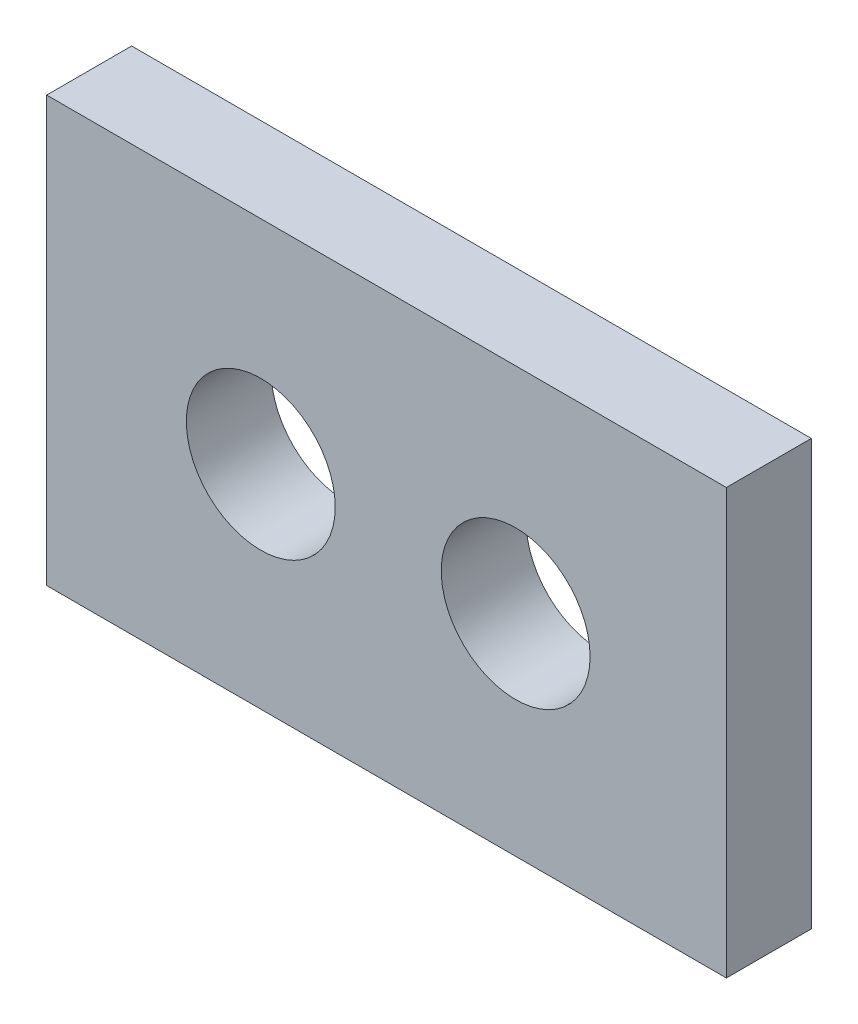
from build123d import *

# Parameters (mm, degrees)
SKETCH_1_W      = 16
SKETCH_1_H      = 10
SKETCH_1_R      = 1.752491691
EXTRUDE_1_DEPTH = 2


with BuildPart() as part:
    # 草图1 → 凸台-拉伸1 (new body)
    with BuildSketch(Plane.XY):
        with Locations((8, 5)):
            Rectangle(SKETCH_1_W, SKETCH_1_H)
        with Locations((5.040081237, 4.992802608)):
            Circle(SKETCH_1_R, mode=Mode.SUBTRACT)
        with Locations((11.039908886, 4.947325376)):
            Circle(SKETCH_1_R, mode=Mode.SUBTRACT)
    extrude(amount=EXTRUDE_1_DEPTH)


solid = part.part
